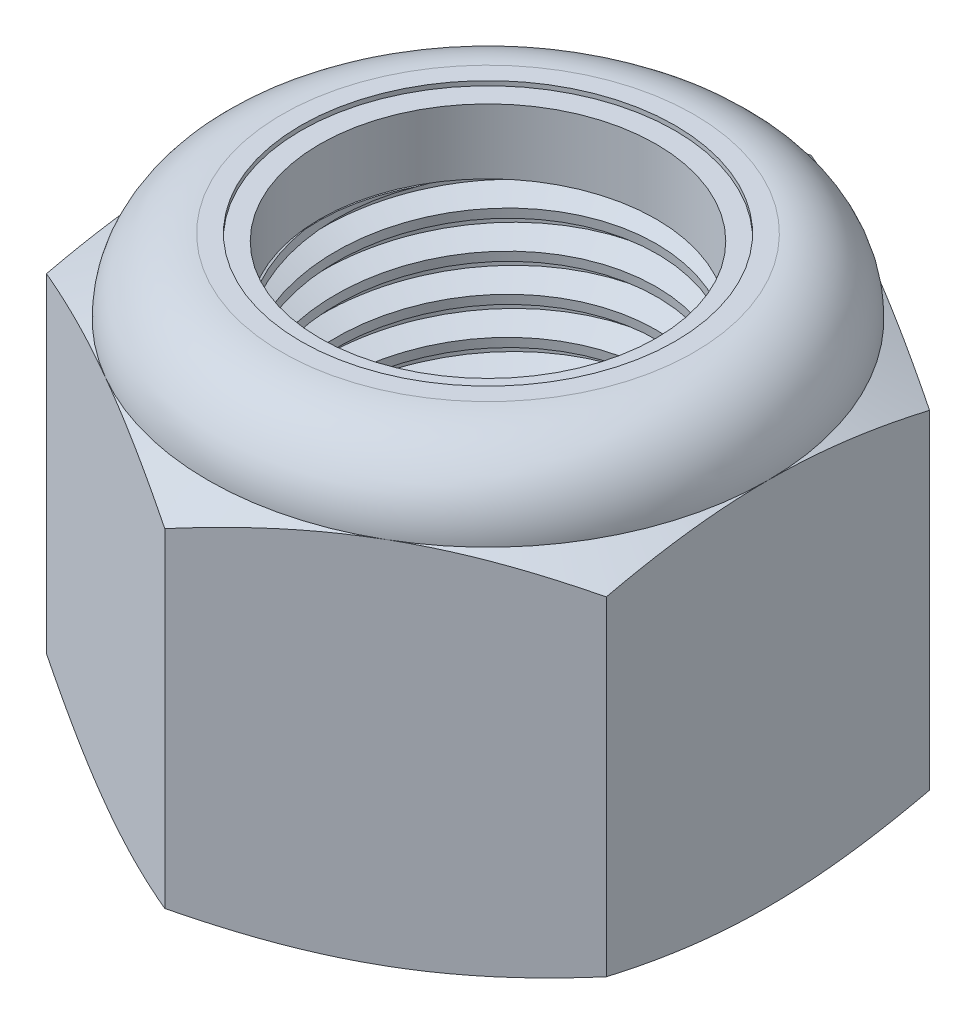
from build123d import *

# Parameters (mm, degrees)
EXTRUDE1_DEPTH      = 15.08125
SKETCH2_W           = 6.35
SKETCH2_H           = 15.08125
LPATTERN1_COUNT     = 12
LPATTERN1_PITCH     = 1.27
LPATTERN1_COL_COUNT = 2
LPATTERN1_COL_PITCH = 1.27


with BuildPart() as part:
    # Sketch1 → Extrude1 (new body)
    with BuildSketch(Plane(origin=(0, 0, 0), x_dir=(1, 0, 0), z_dir=(0, 1, 0))):
        Polygon((0, 10.998522628), (-9.525, 5.499261314), (-9.525, -5.499261314), (0, -10.998522628), (9.525, -5.499261314), (9.525, 5.499261314), align=None)
    extrude(amount=EXTRUDE1_DEPTH)

    # Sketch4 → Cut-Revolve2 (revolve, cut)
    with BuildSketch(Plane(origin=(0, 0, 0), x_dir=(0, 0, -1), z_dir=(1, 0, 0))):
        Polygon((0, 15.08125), (6.35, 15.08125), (5.721290563, 14.788077975), (5.721290563, 0.293172025), (6.35, 0), (0, 0), align=None)
    revolve(axis=Axis((0, 15.08125, 0), (0, 1, 0)), mode=Mode.SUBTRACT)


with BuildPart() as body_2:
    # Sketch2 → Revolve1 (revolve)
    with BuildSketch(Plane(origin=(0, 0, 0), x_dir=(0, 0, -1), z_dir=(1, 0, 0))):
        with Locations((3.175, 7.540625)):
            Rectangle(SKETCH2_W, SKETCH2_H)
    revolve(axis=Axis((0, -6.35, 0), (0, 1, 0)))

    # Sketch3 → Cut-Revolve1 (revolve, cut)
    with BuildSketch(Plane(origin=(0, 0, 0), x_dir=(0, 0, -1), z_dir=(1, 0, 0))):
        Polygon((6.365796215, 14.923287846), (6.476369723, 13.817552768), (5.752882994, 14.144058534), (5.721290563, 14.459982842), align=None)
    cut_revolve1 = revolve(axis=Axis((0, 15.08125, 0.135293799), (0, -0.99503719, -0.099503719)), mode=Mode.SUBTRACT)

    # LPattern1: Cut-Revolve1 ×12
    with Locations(*[(0, -i * LPATTERN1_PITCH, 0) for i in range(1, LPATTERN1_COUNT)]):
        add(cut_revolve1, mode=Mode.SUBTRACT)

    # LPattern1 col: Cut-Revolve1 ×2
    with Locations(*[(0, i * LPATTERN1_COL_PITCH, 0) for i in range(1, LPATTERN1_COL_COUNT)]):
        add(cut_revolve1, mode=Mode.SUBTRACT)


with BuildPart() as part_1:
    add(part.part)

    # Combine1: cut body 2
    add(body_2.part, mode=Mode.SUBTRACT)

    # Sketch5 → Cut-Revolve3 (revolve, cut)
    with BuildSketch(Plane(origin=(0, 0, 0), x_dir=(0, 0, -1), z_dir=(1, 0, 0))):
        with BuildLine():
            Line((0, 0), (9.525, 0))
            Line((9.525, 0), (10.998522628, 0.687114886))
            Line((10.998522628, 0.687114886), (10.998522628, 11.880593447))
            Line((10.998522628, 11.880593447), (9.525, 12.567708333))
            ThreePointArc((9.525, 12.567708333), (8.788800691, 14.345050691), (7.011458333, 15.08125))
            Line((7.011458333, 15.08125), (7.011458333, 16.35125))
            Line((7.011458333, 16.35125), (12.268522628, 16.35125))
            Line((12.268522628, 16.35125), (12.268522628, -1.27))
            Line((12.268522628, -1.27), (0, -1.27))
            Line((0, -1.27), (0, 0))
        make_face()
    revolve(axis=Axis((0, 0, 0), (0, 1, 0)), mode=Mode.SUBTRACT)

    # Sketch6 → Cut-Revolve4 (revolve, cut)
    with BuildSketch(Plane(origin=(0, 0, 0), x_dir=(0, 0, -1), z_dir=(1, 0, 0))):
        with BuildLine():
            Line((0, 12.567708333), (9.3726, 12.567708333))
            ThreePointArc((9.3726, 12.567708333), (8.681037617, 14.237287617), (7.011458333, 14.92885))
            Line((7.011458333, 14.92885), (6.366374448, 14.92885))
            Line((6.366374448, 14.92885), (6.366374448, 16.35125))
            Line((6.366374448, 16.35125), (0, 16.35125))
            Line((0, 16.35125), (0, 12.567708333))
        make_face()
    revolve(axis=Axis((0, 16.35125, 0), (0, 1, 0)), mode=Mode.SUBTRACT)


with BuildPart() as body_2_2:
    # Sketch7 → Revolve2 (revolve)
    with BuildSketch(Plane(origin=(0, 0, 0), x_dir=(0, 0, -1), z_dir=(1, 0, 0))):
        with BuildLine():
            Line((5.721290563, 12.643908333), (9.295129058, 12.643908333))
            ThreePointArc((9.295129058, 12.643908333), (8.599986877, 14.210125907), (7.011458333, 14.85265))
            Line((7.011458333, 14.85265), (5.721290563, 14.85265))
            Line((5.721290563, 14.85265), (5.721290563, 12.643908333))
        make_face()
    revolve(axis=Axis((0, 12.643908333, 0), (0, 1, 0)))


solid = Compound([part_1.part, body_2_2.part])
